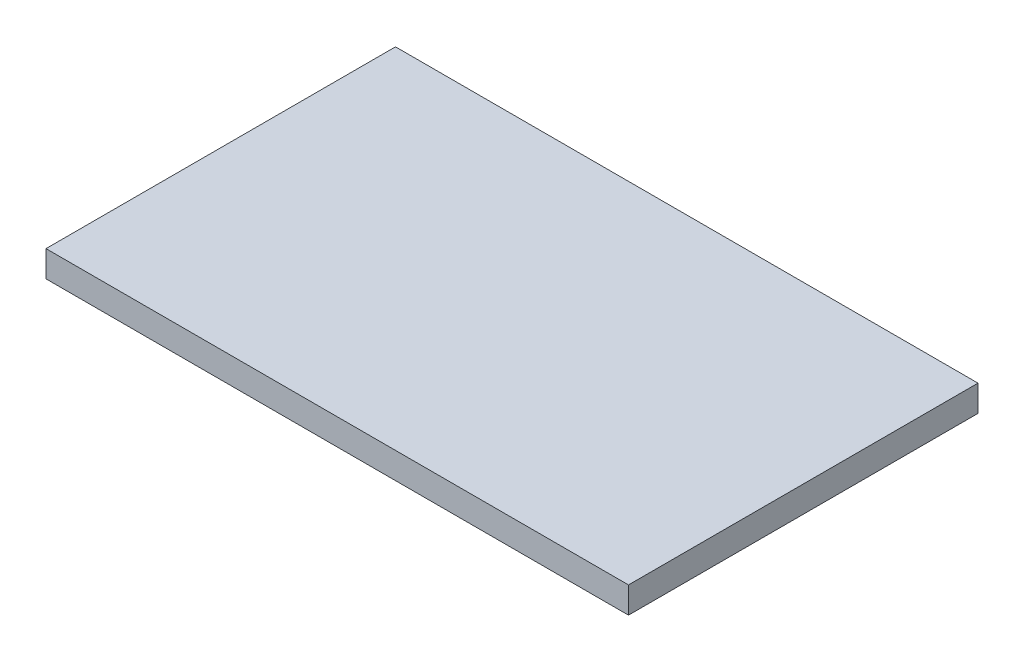
from build123d import *

# Parameters (mm, degrees)
SKETCH1_W           = 10
SKETCH1_H           = 6
BOSS_EXTRUDE1_DEPTH = 0.45


with BuildPart() as part:
    # Sketch1 → Boss-Extrude1 (new body)
    with BuildSketch(Plane(origin=(0, 0, 0), x_dir=(1, 0, 0), z_dir=(0, 1, 0))):
        with Locations((5, 3)):
            Rectangle(SKETCH1_W, SKETCH1_H)
    extrude(amount=BOSS_EXTRUDE1_DEPTH)


solid = part.part
